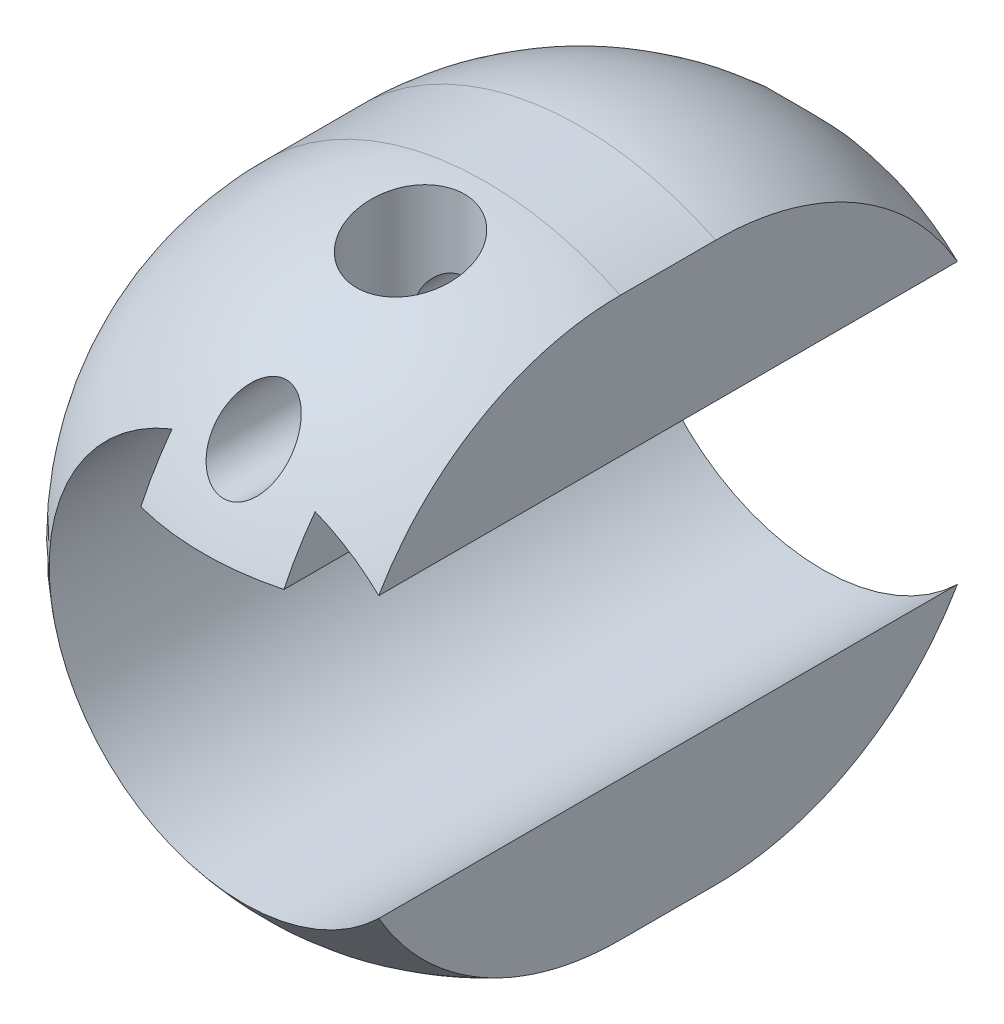
from build123d import *

# Parameters (mm, degrees)
BODY_ANGLE                  = 180
HOLE_FOR_HANDLE_DEPTH       = 7.5
SKETCH6_R                   = 1.1303
F_5_40_SET_SCREW_HOLE_DEPTH = 7
SKETCH8_R                   = 0.75
HOLE_FOR_CABLE_DEPTH        = 7
SKETCH9_R                   = 6.5
SKETCH9_R_2                 = 0.75
BOSS_EXTRUDE1_DEPTH         = 2
SKETCH10_R                  = 0.8
F_2X0_4_SCREW_HOLE_DEPTH    = 14
SKETCH11_R                  = 1
CUT_EXTRUDE5_DEPTH          = 4
SKETCH12_R                  = 1.875
CUT_EXTRUDE6_DEPTH          = 1.5
REVOLVE4_ANGLE              = 180
SKETCH14_R                  = 0.75
CUT_EXTRUDE7_DEPTH          = 7.5
SKETCH15_W                  = 7.481493474
SKETCH15_H                  = 21.852119754
CUT_EXTRUDE9_DEPTH          = 14.0000001


with BuildPart() as part:
    # Sketch3 → body (revolve)
    with BuildSketch(Plane.XY):
        with BuildLine():
            Line((0, 6.5), (0, -6.5))
            ThreePointArc((0, -6.5), (6.5, 0), (0, 6.5))
        make_face()
    revolve(axis=Axis((0, 6.5, 0), (0, -1, 0)), revolution_arc=BODY_ANGLE)

    # Sketch5 → hole for handle (cut, through all)
    with BuildSketch(Plane(origin=(0, 0, 0), x_dir=(-1, 0, 0), z_dir=(0, 0, -1))):
        with BuildLine():
            Line((1.5, 3.688881761), (1.5, 2.702827207))
            Line((1.5, 2.702827207), (-1.5, 2.702827207))
            Line((-1.5, 2.702827207), (-1.5, 3.688881761))
            Line((-1.5, 3.688881761), (-1.5, 3.788881761))
            ThreePointArc((-1.5, 3.788881761), (0, -4.075), (1.5, 3.788881761))
            Line((1.5, 3.788881761), (1.5, 3.688881761))
        make_face()
    extrude(amount=-HOLE_FOR_HANDLE_DEPTH, mode=Mode.SUBTRACT)

    # Sketch6 → 5-40 set screw hole (cut)
    with BuildSketch(Plane(origin=(0, 6.5, 0), x_dir=(1, 0, 0), z_dir=(0, 1, 0))):
        with Locations((0, -1.564027547)):
            Circle(SKETCH6_R)
    extrude(amount=-F_5_40_SET_SCREW_HOLE_DEPTH, mode=Mode.SUBTRACT)

    # Sketch8 → hole for cable (cut)
    with BuildSketch(Plane(origin=(0, 0, 0), x_dir=(-1, 0, 0), z_dir=(0, 0, -1))):
        with Locations((0, 4.237225844)):
            Circle(SKETCH8_R)
    extrude(amount=-HOLE_FOR_CABLE_DEPTH, mode=Mode.SUBTRACT)

    # Sketch9 → Boss-Extrude1 (add)
    with BuildSketch(Plane(origin=(0, 0, 0), x_dir=(-1, 0, 0), z_dir=(0, 0, -1))):
        Circle(SKETCH9_R)
        with Locations((0, 4.237225844)):
            Circle(SKETCH9_R_2, mode=Mode.SUBTRACT)
        with BuildLine():
            Line((-1.5, 2.702827207), (-1.5, 3.788881761))
            ThreePointArc((-1.5, 3.788881761), (0, -4.075), (1.5, 3.788881761))
            Line((1.5, 3.788881761), (1.5, 2.702827207))
            Line((1.5, 2.702827207), (-1.5, 2.702827207))
        make_face(mode=Mode.SUBTRACT)
    extrude(amount=BOSS_EXTRUDE1_DEPTH)

    # Sketch10 → 2X0.4 screw hole (cut, through all)
    with BuildSketch(Plane(origin=(6.5, 0, 0), x_dir=(0, 0, -1), z_dir=(1, 0, 0))):
        with Locations((-1.067713855, 0)):
            Circle(SKETCH10_R)
    extrude(amount=-F_2X0_4_SCREW_HOLE_DEPTH, mode=Mode.SUBTRACT)

    # Sketch11 → Cut-Extrude5 (cut)
    with BuildSketch(Plane(origin=(6.5, 0, 0), x_dir=(0, 0, -1), z_dir=(1, 0, 0))):
        with Locations((-1.067713855, 0)):
            Circle(SKETCH11_R)
    extrude(amount=-CUT_EXTRUDE5_DEPTH, mode=Mode.SUBTRACT)

    # Sketch12 → Cut-Extrude6 (cut)
    with BuildSketch(Plane(origin=(6.5, 0, 0), x_dir=(0, 0, -1), z_dir=(1, 0, 0))):
        with Locations((-1.067713855, 0)):
            Circle(SKETCH12_R)
    extrude(amount=-CUT_EXTRUDE6_DEPTH, mode=Mode.SUBTRACT)

    # Sketch13 → Revolve4 (revolve)
    with BuildSketch(Plane(origin=(0, 0, -2), x_dir=(-1, 0, 0), z_dir=(0, 0, -1))):
        with BuildLine():
            Line((0, 6.5), (0, -6.5))
            ThreePointArc((0, -6.5), (6.5, 0), (0, 6.5))
        make_face()
    revolve(axis=Axis((0, 6.5, -2), (0, -1, 0)), revolution_arc=REVOLVE4_ANGLE)

    # Sketch14 → Cut-Extrude7 (cut, through all)
    with BuildSketch(Plane.XY.offset(-2)):
        with Locations((0, 4.237225844)):
            Circle(SKETCH14_R)
        with BuildLine():
            Line((1.5, 3.788881761), (1.5, 2.702827207))
            Line((1.5, 2.702827207), (-1.5, 2.702827207))
            Line((-1.5, 2.702827207), (-1.5, 3.788881761))
            ThreePointArc((-1.5, 3.788881761), (0, -4.075), (1.5, 3.788881761))
        make_face()
    extrude(amount=-CUT_EXTRUDE7_DEPTH, mode=Mode.SUBTRACT)

    # Sketch15 → Cut-Extrude9 (cut, through all)
    with BuildSketch(Plane(origin=(0, 6.5, 0), x_dir=(1, 0, 0), z_dir=(0, 1, 0))):
        with Locations((6.572929737, 1.595465377)):
            Rectangle(SKETCH15_W, SKETCH15_H)
    extrude(amount=-CUT_EXTRUDE9_DEPTH, mode=Mode.SUBTRACT)


solid = part.part
